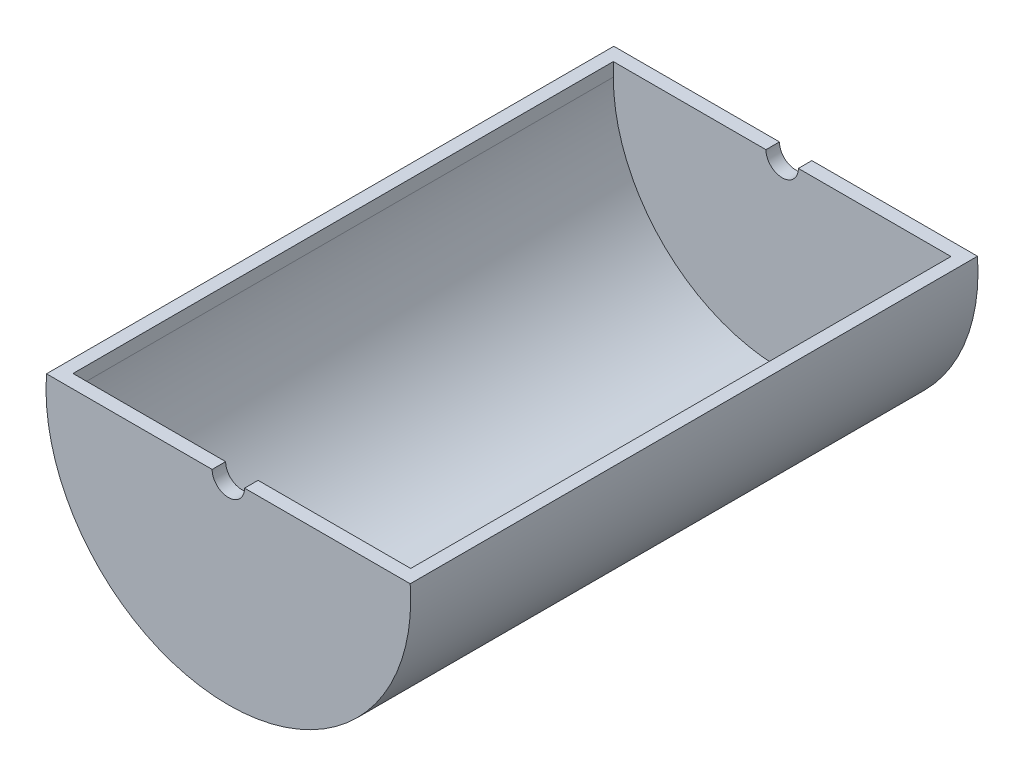
from build123d import *

# Parameters (mm, degrees)
BOSS_EXTRUDE1_DEPTH = 210
BOSS_EXTRUDE2_START = 210
BOSS_EXTRUDE2_DEPTH = 10
BOSS_EXTRUDE3_START = -210
BOSS_EXTRUDE3_DEPTH = 10


with BuildPart() as part:
    # Sketch1 → Boss-Extrude1 (new body, symmetric)
    with BuildSketch(Plane.XY):
        with BuildLine():
            Line((-134.629120178, 10), (-125, 10))
            Line((-125, 10), (-125, 0))
            ThreePointArc((-125, 0), (0, -125), (125, 0))
            Line((125, 0), (125, 10))
            Line((125, 10), (134.629120178, 10))
            ThreePointArc((134.629120178, 10), (0, -135), (-134.629120178, 10))
        make_face()
    extrude(amount=BOSS_EXTRUDE1_DEPTH, both=True)

    # Sketch2 → Boss-Extrude2 (add)
    with BuildSketch(Plane.XY.offset(BOSS_EXTRUDE2_START)):
        with BuildLine():
            Line((-125, 10), (-12, 10))
            ThreePointArc((-12, 10), (0, -2), (12, 10))
            Line((12, 10), (125, 10))
            Line((125, 10), (125, 0))
            ThreePointArc((125, 0), (0, -125), (-125, 0))
            Line((-125, 0), (-125, 10))
        make_face()
    extrude(amount=-BOSS_EXTRUDE2_DEPTH)

    # Sketch2_2 → Boss-Extrude3 (add)
    with BuildSketch(Plane.XY.offset(BOSS_EXTRUDE3_START)):
        with BuildLine():
            Line((-12, 10), (-125, 10))
            Line((-125, 10), (-125, 0))
            ThreePointArc((-125, 0), (0, -125), (125, 0))
            Line((125, 0), (125, 10))
            Line((125, 10), (12, 10))
            ThreePointArc((12, 10), (0, -2), (-12, 10))
        make_face()
        with BuildLine():
            Line((-125, 0), (-125, 10))
            Line((-125, 10), (-134.629120178, 10))
            ThreePointArc((-134.629120178, 10), (0, -135), (134.629120178, 10))
            Line((134.629120178, 10), (125, 10))
            Line((125, 10), (125, 0))
            ThreePointArc((125, 0), (0, -125), (-125, 0))
        make_face()
    extrude(amount=BOSS_EXTRUDE3_DEPTH)


solid = part.part
